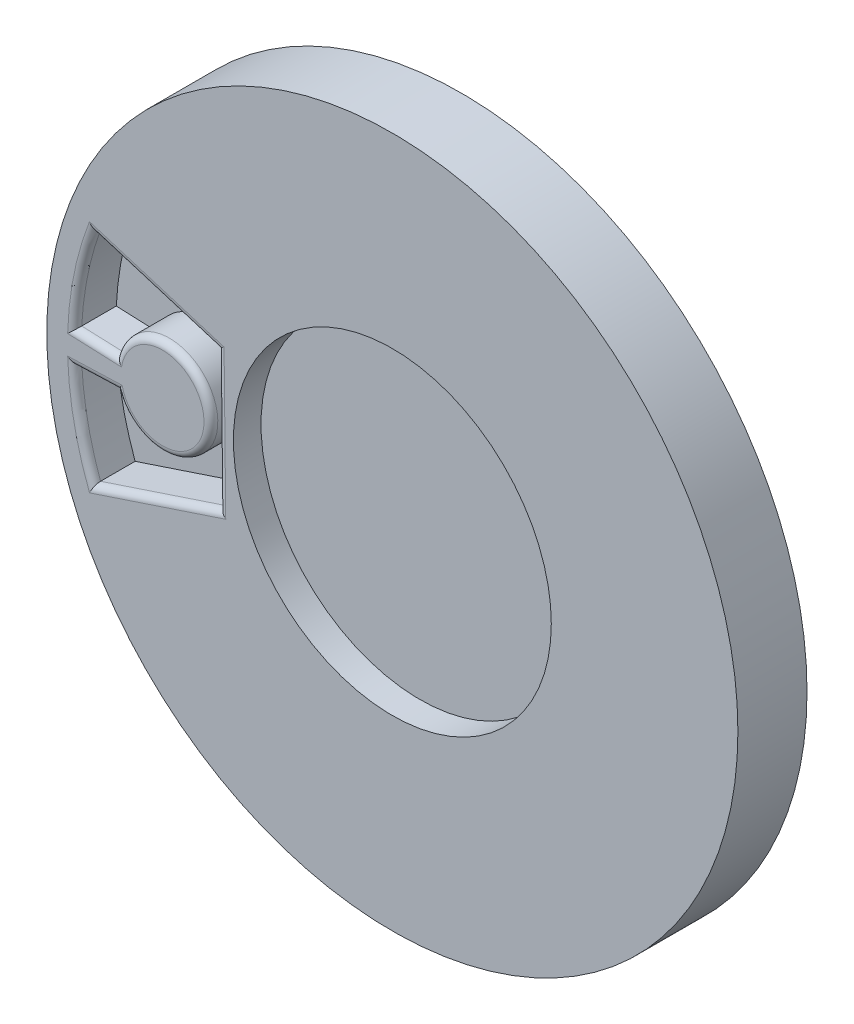
from build123d import *

# Parameters (mm, degrees)
SKETCH1_R           = 25
BOSS_EXTRUDE1_DEPTH = 5
CUT_EXTRUDE1_START  = 5
CUT_EXTRUDE1_DEPTH  = 3
CUT_EXTRUDE2_START  = 5
SKETCH3_R           = 11.5
CUT_EXTRUDE2_DEPTH  = 2
SKETCH4_R           = 4
BOSS_EXTRUDE2_DEPTH = 10
CUT_EXTRUDE3_START  = -10
SKETCH5_W           = 1.2
SKETCH5_H           = 10
CUT_EXTRUDE3_DEPTH  = 5
FILLET1_R           = 0.5


with BuildPart() as part:
    # Sketch1 → Boss-Extrude1 (new body)
    with BuildSketch(Plane.XY):
        Circle(SKETCH1_R)
    extrude(amount=BOSS_EXTRUDE1_DEPTH)

    # Sketch2 → Cut-Extrude1 (cut)
    with BuildSketch(Plane.XY.offset(CUT_EXTRUDE1_START)):
        with BuildLine():
            Line((-19.920587104, -1.094962553), (-22.96853355, -1.202691377))
            ThreePointArc((-22.96853355, -1.202691377), (-22.537445492, -4.589504406), (-21.609752304, -7.875189228))
            Line((-21.609752304, -7.875189228), (-12.555769306, -4.868581062))
            Line((-12.555769306, -4.868581062), (-12.669871245, 5.133277845))
            Line((-12.669871245, 5.133277845), (-21.609327517, 7.876354758))
            ThreePointArc((-21.609327517, 7.876354758), (-22.540397078, 4.574986289), (-22.970127121, 1.171861786))
            Line((-22.970127121, 1.171861786), (-19.990271583, 1.051061802))
            ThreePointArc((-19.990271583, 1.051061802), (-13.12774726, 0.199754222), (-19.920587104, -1.094962553))
        make_face()
    extrude(amount=-CUT_EXTRUDE1_DEPTH, mode=Mode.SUBTRACT)

    # Sketch3 → Cut-Extrude2 (cut)
    with BuildSketch(Plane.XY.offset(CUT_EXTRUDE2_START)):
        Circle(SKETCH3_R)
    extrude(amount=-CUT_EXTRUDE2_DEPTH, mode=Mode.SUBTRACT)

    # Sketch4 → Boss-Extrude2 (add)
    with BuildSketch(Plane.XY):
        Circle(SKETCH4_R)
    extrude(amount=-BOSS_EXTRUDE2_DEPTH)

    # Sketch5 → Cut-Extrude3 (cut)
    with BuildSketch(Plane.XY.offset(CUT_EXTRUDE3_START)):
        Rectangle(SKETCH5_W, SKETCH5_H)
    extrude(amount=CUT_EXTRUDE3_DEPTH, mode=Mode.SUBTRACT)

    # Fillet1
    fillet1_edges = [part.edges().sort_by_distance(p)[0] for p in [
        (-17.082760805, -6.371885145, 5),
        (-21.444560327, -1.148826965, 5),
        (-13.12774726, 0.199754222, 5),
        (-21.480199352, 1.111461794, 5),
        (-22.540397078, 4.574986289, 5),
        (-22.537445492, -4.589504406, 5),
        (-17.139599381, 6.504816302, 5),
        (-12.612820275, 0.132348391, 5),
    ]]
    fillet(fillet1_edges, radius=FILLET1_R)


solid = part.part
